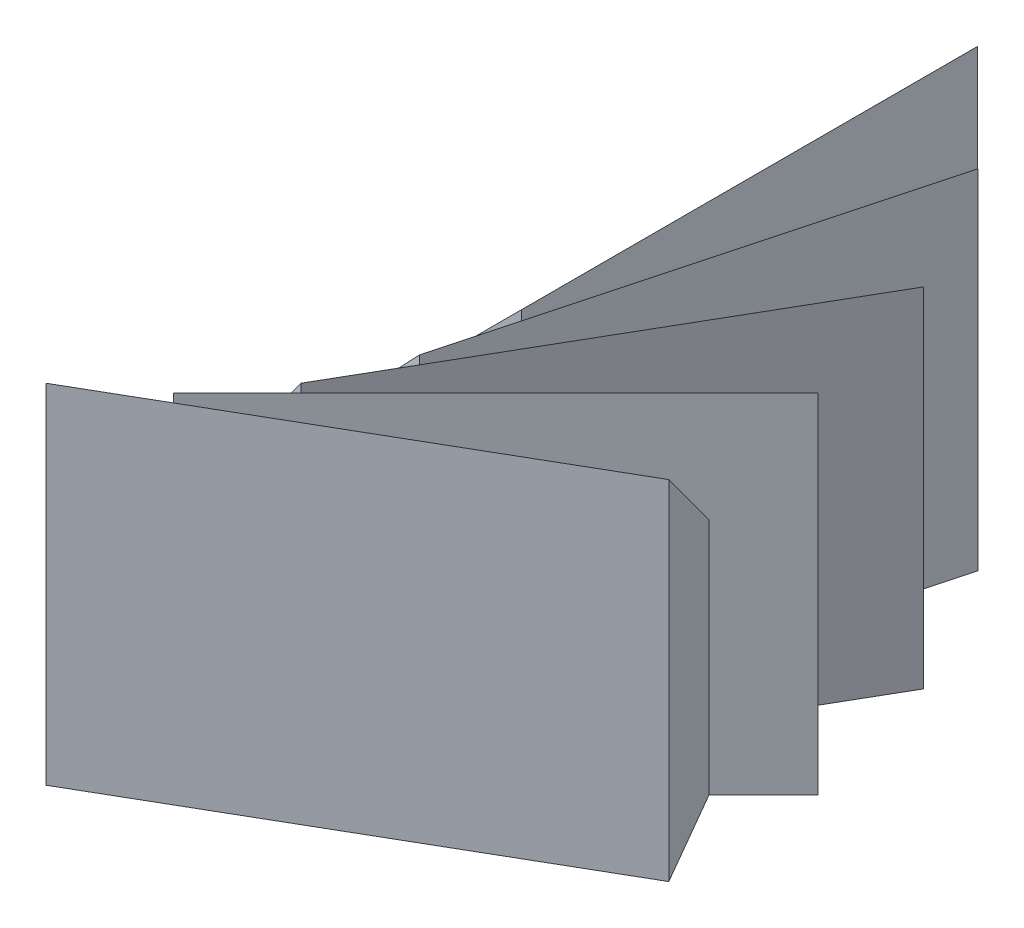
from build123d import *

# Parameters (mm, degrees)
AUFSATZ_LINEAR_AUSTRAGEN1_DEPTH = 19
KREISMUSTER1_COUNT              = 5
KREISMUSTER1_ANGLE              = 60


with BuildPart() as part:
    # Skizze2 → Aufsatz-Linear austragen1 (new body)
    with BuildSketch(Plane.XY):
        Polygon((55.173482404, 0), (69.682060417, 14.508578013), (69.682060417, 0), align=None)
    aufsatz_linear_austragen1 = extrude(amount=-AUFSATZ_LINEAR_AUSTRAGEN1_DEPTH)

    # Kreismuster1: Aufsatz-Linear austragen1 ×5 about axis
    kreismuster1_axis = Axis((55.173482404, 0, 0), (0, -1, 0))
    for i in range(1, KREISMUSTER1_COUNT):
        add(aufsatz_linear_austragen1.rotate(kreismuster1_axis, i * KREISMUSTER1_ANGLE / (KREISMUSTER1_COUNT - 1)))


solid = part.part
